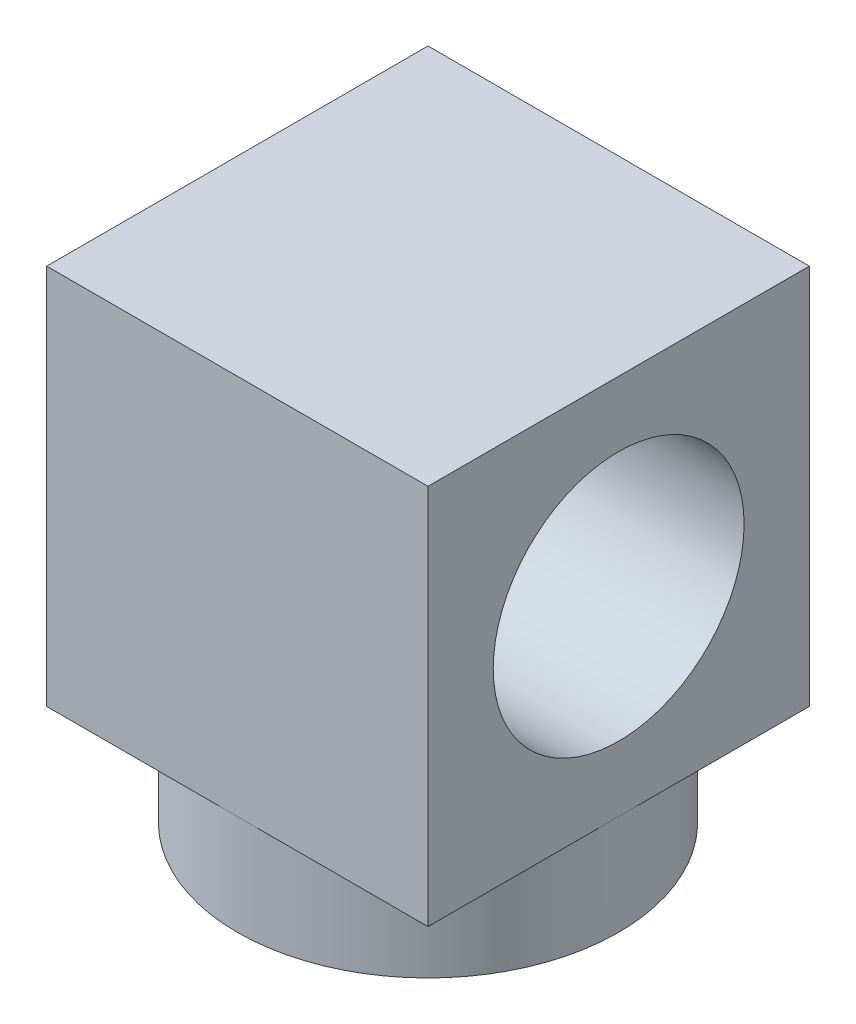
from build123d import *

# Parameters (mm, degrees)
SKETCH1_R           = 4.826
BOSS_EXTRUDE1_DEPTH = 2.54
SKETCH2_W           = 9.652
SKETCH2_H           = 9.652
BOSS_EXTRUDE2_DEPTH = 9.652
SKETCH3_R           = 3.175
CUT_EXTRUDE1_DEPTH  = 9.652


with BuildPart() as part:
    # Sketch1 → Boss-Extrude1 (new body)
    with BuildSketch(Plane(origin=(0, 0, 0), x_dir=(1, 0, 0), z_dir=(0, 1, 0))):
        Circle(SKETCH1_R)
    extrude(amount=BOSS_EXTRUDE1_DEPTH)

    # Sketch2 → Boss-Extrude2 (add)
    with BuildSketch(Plane(origin=(0, 2.54, 0), x_dir=(1, 0, 0), z_dir=(0, 1, 0))):
        Rectangle(SKETCH2_W, SKETCH2_H)
    extrude(amount=BOSS_EXTRUDE2_DEPTH)

    # Sketch3 → Cut-Extrude1 (cut)
    with BuildSketch(Plane(origin=(4.826, 0, 0), x_dir=(0, 0, -1), z_dir=(1, 0, 0))):
        with Locations((0, 7.366)):
            Circle(SKETCH3_R)
    extrude(amount=-CUT_EXTRUDE1_DEPTH, mode=Mode.SUBTRACT)


solid = part.part
